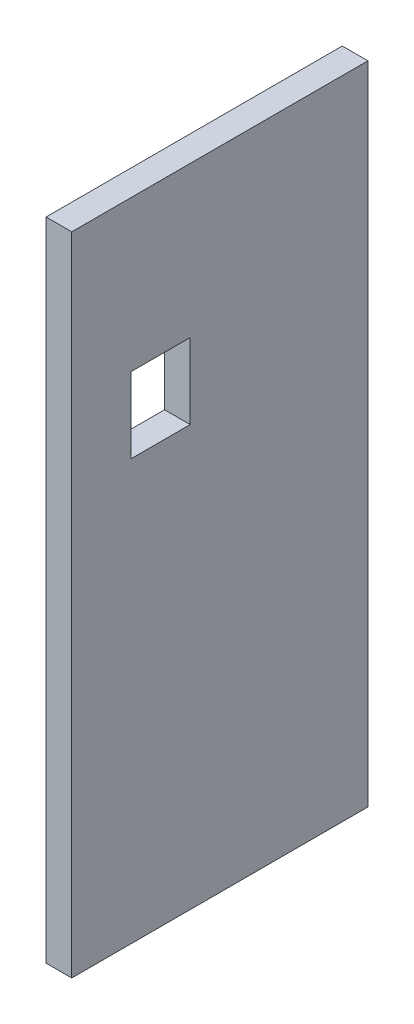
from build123d import *

# Parameters (mm, degrees)
SKETCH1_W           = 55
SKETCH1_H           = 120
BOSS_EXTRUDE1_DEPTH = 4.7625
SKETCH2_W           = 11
SKETCH2_H           = 14
CUT_EXTRUDE1_DEPTH  = 5.7625


with BuildPart() as part:
    # Sketch1 → Boss-Extrude1 (new body)
    with BuildSketch(Plane(origin=(0, 0, 0), x_dir=(0, 0, -1), z_dir=(1, 0, 0))):
        Rectangle(SKETCH1_W, SKETCH1_H)
    extrude(amount=BOSS_EXTRUDE1_DEPTH)

    # Sketch2 → Cut-Extrude1 (cut, through all)
    with BuildSketch(Plane.ZY):
        with Locations((11, 25)):
            Rectangle(SKETCH2_W, SKETCH2_H)
    extrude(amount=-CUT_EXTRUDE1_DEPTH, mode=Mode.SUBTRACT)


solid = part.part
